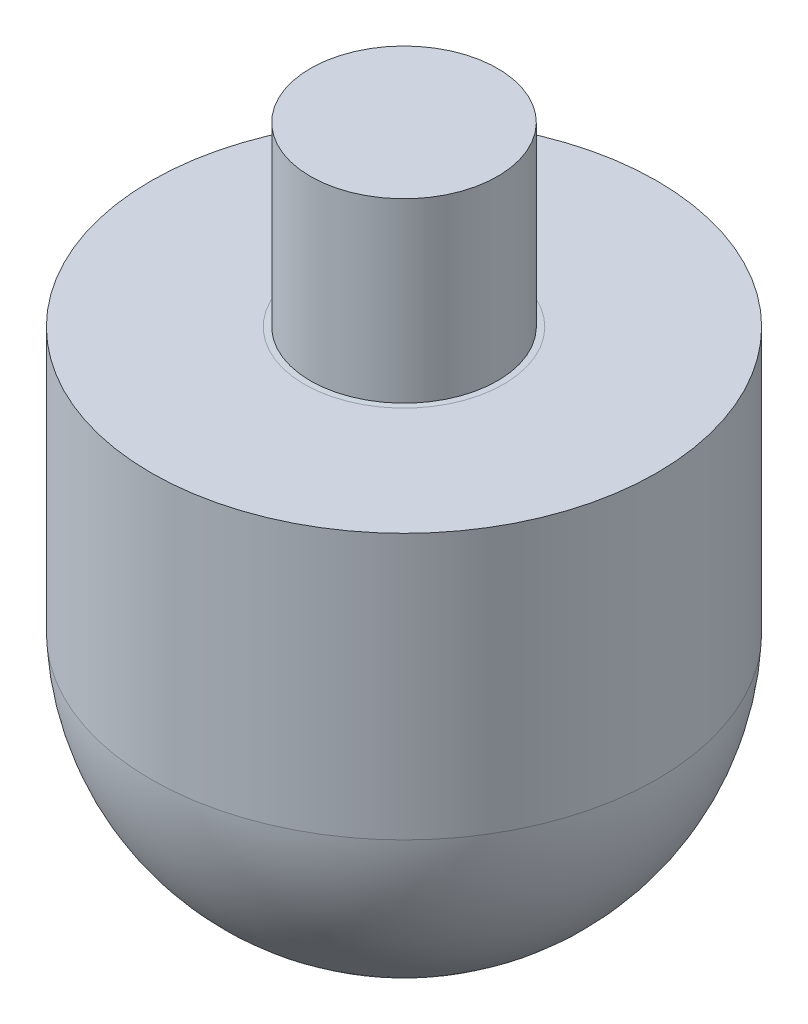
from build123d import *


with BuildPart() as part:
    # Sketch1 → Revolve1 (revolve)
    with BuildSketch(Plane.XY, mode=Mode.PRIVATE) as revolve1_sk:
        with BuildLine():
            Line((0, 25.000131346), (0, -13.644758808))
            ThreePointArc((0, -13.644758808), (9.877596263, -9.685507344), (14.285943751, 0))
            Line((14.285943751, 0), (14.285943751, 14.997751876))
            Line((14.285943751, 14.997751876), (5.625, 14.997751876))
            Line((5.625, 14.997751876), (5.285944065, 15.000131346))
            Line((5.285944065, 15.000131346), (5.285944065, 25.000131346))
            Line((5.285944065, 25.000131346), (0, 25.000131346))
        make_face()
    revolve(revolve1_sk.sketch.rotate(Axis((0, 25.000131346, 0), (0, -1, 0)), 90), axis=Axis((0, 25.000131346, 0), (0, -1, 0)))  # turned: the seam where the file's is


solid = part.part
